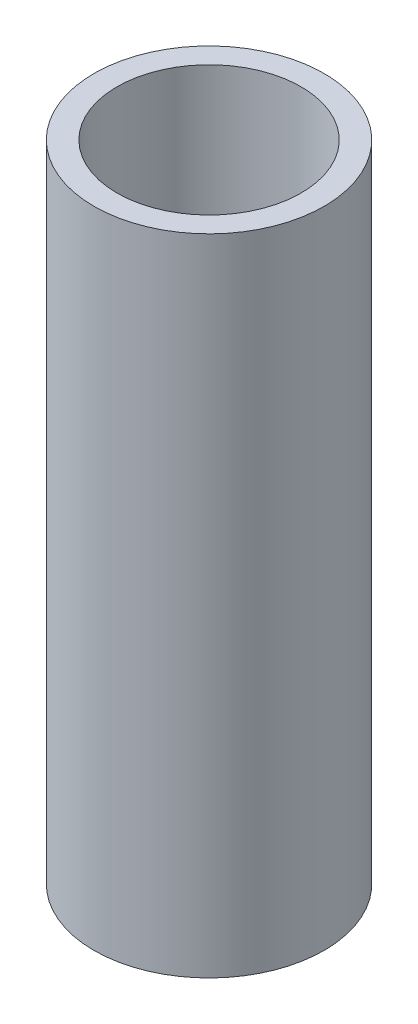
from build123d import *

# Parameters (mm, degrees)
CROQUIS1_R              = 12.5
CROQUIS1_R_2            = 10
SALIENTE_EXTRUIR1_DEPTH = 35


with BuildPart() as part:
    # Croquis1 → Saliente-Extruir1 (new body, symmetric)
    with BuildSketch(Plane(origin=(0, 0, 0), x_dir=(1, 0, 0), z_dir=(0, 1, 0))):
        Circle(CROQUIS1_R)
        Circle(CROQUIS1_R_2, mode=Mode.SUBTRACT)
    extrude(amount=SALIENTE_EXTRUIR1_DEPTH, both=True)


solid = part.part
